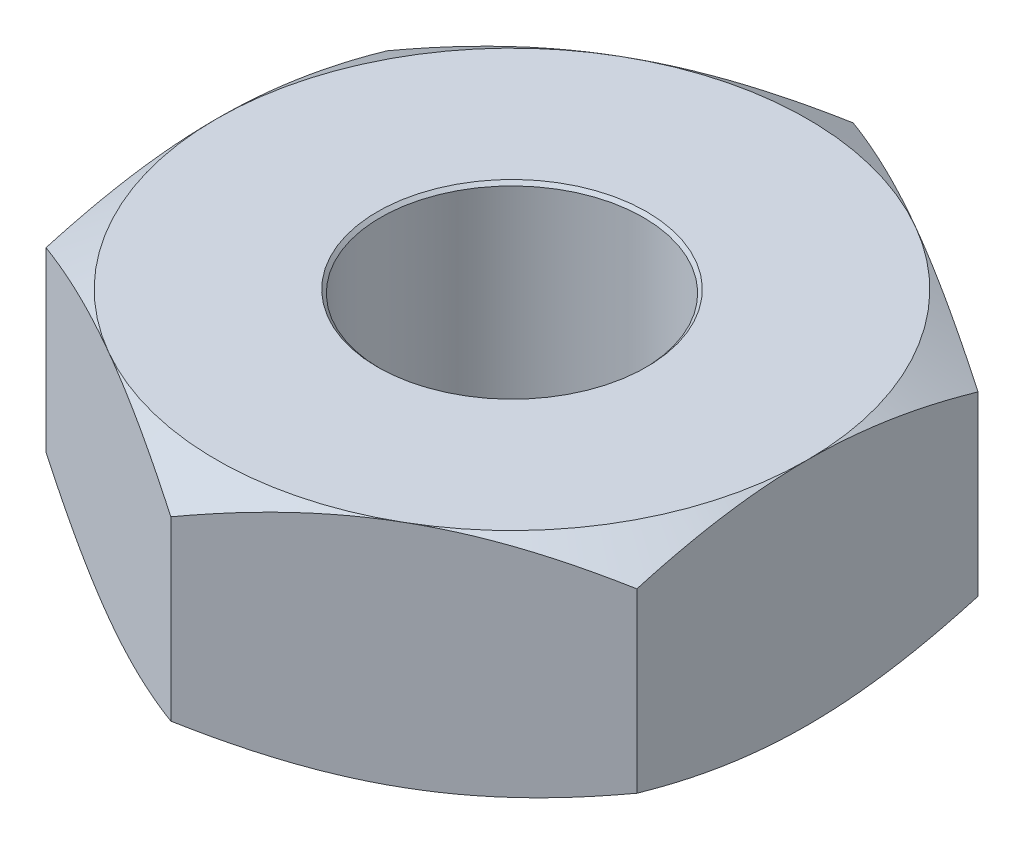
from build123d import *

# Parameters (mm, degrees)
SKETCH1_R           = 1
BOSS_EXTRUDE1_DEPTH = 1.75
SKETCH2_OUTSIDE_W   = 13.98
SKETCH2_OUTSIDE_H   = 14.676
SKETCH2_OUTSIDE_R   = 2.25
CUT_EXTRUDE1_DEPTH  = 1.75
CUT_EXTRUDE1_TAPER  = 60
SKETCH3_OUTSIDE_W   = 13.98
SKETCH3_OUTSIDE_H   = 14.676
SKETCH3_OUTSIDE_R   = 2.25
CUT_EXTRUDE3_DEPTH  = 1.75
CUT_EXTRUDE3_TAPER  = 60
CHAMFER1_SIZE       = 0.025


with BuildPart() as part:
    # Sketch1 → Boss-Extrude1 (new body)
    with BuildSketch(Plane(origin=(0, 0, 0), x_dir=(1, 0, 0), z_dir=(0, 1, 0))):
        Polygon((0, -2.598076211), (2.25, -1.299038106), (2.25, 1.299038106), (0, 2.598076211), (-2.25, 1.299038106), (-2.25, -1.299038106), align=None)
        Circle(SKETCH1_R, mode=Mode.SUBTRACT)
    extrude(amount=BOSS_EXTRUDE1_DEPTH)

    # Sketch2 outside → Cut-Extrude1 (cut)
    with BuildSketch(Plane(origin=(0, 1.75, 0), x_dir=(1, 0, 0), z_dir=(0, 1, 0))):
        Rectangle(SKETCH2_OUTSIDE_W, SKETCH2_OUTSIDE_H)
        Circle(SKETCH2_OUTSIDE_R, mode=Mode.SUBTRACT)
    extrude(amount=-CUT_EXTRUDE1_DEPTH, taper=CUT_EXTRUDE1_TAPER, mode=Mode.SUBTRACT)

    # Sketch3 outside → Cut-Extrude3 (cut)
    with BuildSketch(Plane.XZ):
        Rectangle(SKETCH3_OUTSIDE_W, SKETCH3_OUTSIDE_H)
        Circle(SKETCH3_OUTSIDE_R, mode=Mode.SUBTRACT)
    extrude(amount=-CUT_EXTRUDE3_DEPTH, taper=CUT_EXTRUDE3_TAPER, mode=Mode.SUBTRACT)

    # Chamfer1
    chamfer1_edges = [part.edges().sort_by_distance(p)[0] for p in [
        (-1, 0, 0),
        (-1, 1.75, 0),
    ]]
    chamfer(chamfer1_edges, length=CHAMFER1_SIZE)


solid = part.part
